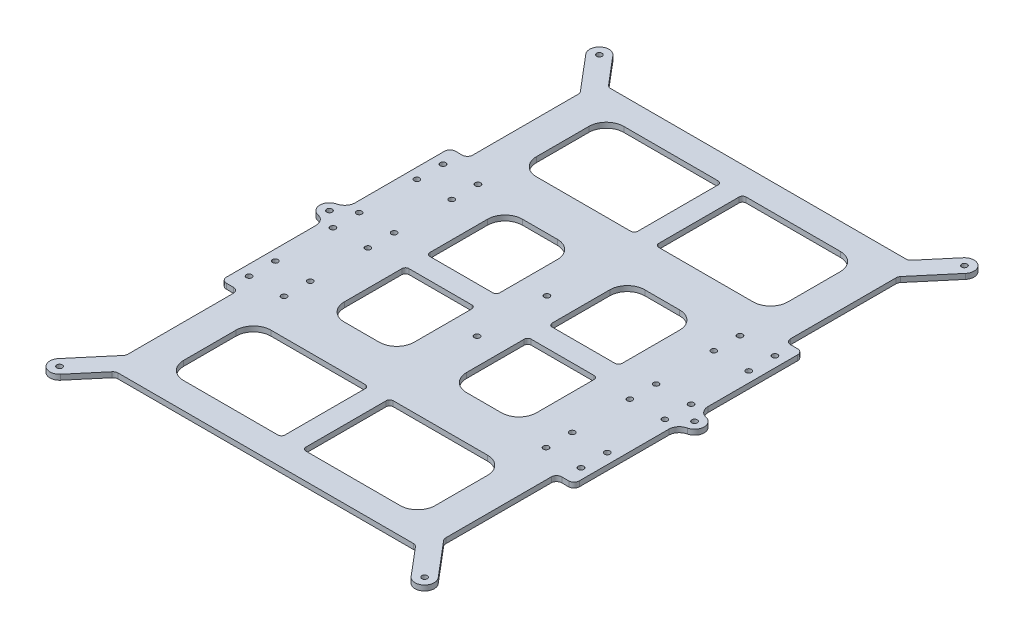
from build123d import *

# Parameters (mm, degrees)
CROQUIS1_W              = 220
CROQUIS1_H              = 320
CROQUIS1_R              = 1.55
CROQUIS1_R_2            = 1.575
SALIENTE_EXTRUIR1_DEPTH = 3
CROQUIS2_OUTSIDE_W      = 299.668
CROQUIS2_OUTSIDE_H      = 399.668
CORTAR_EXTRUIR1_DEPTH   = 3
REDONDEO1_R             = 3


with BuildPart() as part:
    # Croquis1 → Saliente-Extruir1 (new body)
    with BuildSketch(Plane(origin=(0, 0, 0), x_dir=(1, 0, 0), z_dir=(0, 1, 0))):
        with Locations((110, 160)):
            Rectangle(CROQUIS1_W, CROQUIS1_H)
        with Locations((185, 167.5)):
            Circle(CROQUIS1_R, mode=Mode.SUBTRACT)
        with Locations((205, 167.5)):
            Circle(CROQUIS1_R, mode=Mode.SUBTRACT)
        with Locations((185, 152.5)):
            Circle(CROQUIS1_R, mode=Mode.SUBTRACT)
        with Locations((205, 152.5)):
            Circle(CROQUIS1_R, mode=Mode.SUBTRACT)
        with Locations((35, 215.5)):
            Circle(CROQUIS1_R_2, mode=Mode.SUBTRACT)
        with Locations((35, 200.5)):
            Circle(CROQUIS1_R_2, mode=Mode.SUBTRACT)
        with Locations((35, 119.5)):
            Circle(CROQUIS1_R_2, mode=Mode.SUBTRACT)
        with Locations((35, 104.5)):
            Circle(CROQUIS1_R_2, mode=Mode.SUBTRACT)
        with Locations((5.5, 314.5)):
            Circle(CROQUIS1_R_2, mode=Mode.SUBTRACT)
        with Locations((214.5, 314.5)):
            Circle(CROQUIS1_R_2, mode=Mode.SUBTRACT)
        with Locations((214.5, 5.5)):
            Circle(CROQUIS1_R_2, mode=Mode.SUBTRACT)
        with Locations((5.5, 5.5)):
            Circle(CROQUIS1_R_2, mode=Mode.SUBTRACT)
        with Locations((15, 200.5)):
            Circle(CROQUIS1_R_2, mode=Mode.SUBTRACT)
        with Locations((15, 215.5)):
            Circle(CROQUIS1_R_2, mode=Mode.SUBTRACT)
        with Locations((15, 104.5)):
            Circle(CROQUIS1_R_2, mode=Mode.SUBTRACT)
        with Locations((15, 119.5)):
            Circle(CROQUIS1_R_2, mode=Mode.SUBTRACT)
        with Locations((110, 180)):
            Circle(CROQUIS1_R_2, mode=Mode.SUBTRACT)
        with Locations((110, 140)):
            Circle(CROQUIS1_R_2, mode=Mode.SUBTRACT)
        with Locations((185, 104.5)):
            Circle(CROQUIS1_R_2, mode=Mode.SUBTRACT)
        with Locations((205, 104.5)):
            Circle(CROQUIS1_R_2, mode=Mode.SUBTRACT)
        with Locations((205, 119.5)):
            Circle(CROQUIS1_R_2, mode=Mode.SUBTRACT)
        with Locations((185, 119.5)):
            Circle(CROQUIS1_R_2, mode=Mode.SUBTRACT)
        with Locations((185, 200.5)):
            Circle(CROQUIS1_R_2, mode=Mode.SUBTRACT)
        with Locations((185, 215.5)):
            Circle(CROQUIS1_R_2, mode=Mode.SUBTRACT)
        with Locations((205, 200.5)):
            Circle(CROQUIS1_R_2, mode=Mode.SUBTRACT)
        with Locations((205, 215.5)):
            Circle(CROQUIS1_R_2, mode=Mode.SUBTRACT)
        with Locations((5.5, 160)):
            Circle(CROQUIS1_R_2, mode=Mode.SUBTRACT)
        with Locations((35, 152.5)):
            Circle(CROQUIS1_R, mode=Mode.SUBTRACT)
        with Locations((15, 152.5)):
            Circle(CROQUIS1_R, mode=Mode.SUBTRACT)
        with Locations((15, 167.5)):
            Circle(CROQUIS1_R, mode=Mode.SUBTRACT)
        with Locations((35, 167.5)):
            Circle(CROQUIS1_R, mode=Mode.SUBTRACT)
        with Locations((214.5, 160)):
            Circle(CROQUIS1_R_2, mode=Mode.SUBTRACT)
    extrude(amount=SALIENTE_EXTRUIR1_DEPTH)

    # Croquis2 outside → Cortar-Extruir1 (cut)
    with BuildSketch(Plane(origin=(0, 3, 0), x_dir=(1, 0, 0), z_dir=(0, 1, 0))):
        with Locations((110, 160)):
            Rectangle(CROQUIS2_OUTSIDE_W, CROQUIS2_OUTSIDE_H)
        with BuildLine():
            Line((9, 148.77502784), (9, 94.5))
            Line((9, 94.5), (19, 94.5))
            Line((19, 94.5), (19, 30))
            Line((19, 30), (1.298802547, 9.049639413))
            ThreePointArc((1.298802547, 9.049639413), (1.950360587, 1.298802547), (9.701197453, 1.950360587))
            Line((9.701197453, 1.950360587), (24.106631311, 19))
            Line((24.106631311, 19), (195.893368689, 19))
            Line((195.893368689, 19), (210.298802547, 1.950360587))
            ThreePointArc((210.298802547, 1.950360587), (218.049639413, 1.298802547), (218.701197453, 9.049639413))
            Line((218.701197453, 9.049639413), (201, 30))
            Line((201, 30), (201, 94.5))
            Line((201, 94.5), (211, 94.5))
            Line((211, 94.5), (211, 148.77502784))
            ThreePointArc((211, 148.77502784), (212.318863014, 152.528287293), (215.695652174, 154.631535054))
            ThreePointArc((215.695652174, 154.631535054), (220, 160), (215.695652174, 165.368464946))
            ThreePointArc((215.695652174, 165.368464946), (212.318863014, 167.471712707), (211, 171.22497216))
            Line((211, 171.22497216), (211, 225.5))
            Line((211, 225.5), (201, 225.5))
            Line((201, 225.5), (201, 290))
            Line((201, 290), (218.701197453, 310.950360587))
            ThreePointArc((218.701197453, 310.950360587), (218.049639413, 318.701197453), (210.298802547, 318.049639413))
            Line((210.298802547, 318.049639413), (195.893368689, 301))
            Line((195.893368689, 301), (24.106631311, 301))
            Line((24.106631311, 301), (9.701197453, 318.049639413))
            ThreePointArc((9.701197453, 318.049639413), (1.950360587, 318.701197453), (1.298802547, 310.950360587))
            Line((1.298802547, 310.950360587), (19, 290))
            Line((19, 290), (19, 225.5))
            Line((19, 225.5), (9, 225.5))
            Line((9, 225.5), (9, 171.22497216))
            ThreePointArc((9, 171.22497216), (7.681136986, 167.471712707), (4.304347826, 165.368464946))
            ThreePointArc((4.304347826, 165.368464946), (0, 160), (4.304347826, 154.631535054))
            ThreePointArc((4.304347826, 154.631535054), (7.681136986, 152.528287293), (9, 148.77502784))
        make_face(mode=Mode.SUBTRACT)
        with BuildLine():
            Line((182, 276), (182, 246))
            ThreePointArc((182, 246), (179.071067812, 238.928932188), (172, 236))
            Line((172, 236), (118, 236))
            ThreePointArc((118, 236), (116.585786438, 236.585786438), (116, 238))
            Line((116, 238), (116, 284))
            ThreePointArc((116, 284), (116.585786438, 285.414213562), (118, 286))
            Line((118, 286), (172, 286))
            ThreePointArc((172, 286), (179.071067812, 283.071067812), (182, 276))
        make_face()
        with BuildLine():
            Line((102, 286), (48, 286))
            ThreePointArc((48, 286), (40.928932188, 283.071067812), (38, 276))
            Line((38, 276), (38, 246))
            ThreePointArc((38, 246), (40.928932188, 238.928932188), (48, 236))
            Line((48, 236), (102, 236))
            ThreePointArc((102, 236), (103.414213562, 236.585786438), (104, 238))
            Line((104, 238), (104, 284))
            ThreePointArc((104, 284), (103.414213562, 285.414213562), (102, 286))
        make_face()
        with BuildLine():
            Line((102, 84), (48, 84))
            ThreePointArc((48, 84), (40.928932188, 81.071067812), (38, 74))
            Line((38, 74), (38, 44))
            ThreePointArc((38, 44), (40.928932188, 36.928932188), (48, 34))
            Line((48, 34), (102, 34))
            ThreePointArc((102, 34), (103.414213562, 34.585786438), (104, 36))
            Line((104, 36), (104, 82))
            ThreePointArc((104, 82), (103.414213562, 83.414213562), (102, 84))
        make_face()
        with BuildLine():
            Line((116, 36), (116, 82))
            ThreePointArc((116, 82), (116.585786438, 83.414213562), (118, 84))
            Line((118, 84), (172, 84))
            ThreePointArc((172, 84), (179.071067812, 81.071067812), (182, 74))
            Line((182, 74), (182, 44))
            ThreePointArc((182, 44), (179.071067812, 36.928932188), (172, 34))
            Line((172, 34), (118, 34))
            ThreePointArc((118, 34), (116.585786438, 34.585786438), (116, 36))
        make_face()
        with BuildLine():
            Line((55, 152), (55, 119))
            ThreePointArc((55, 119), (57.928932188, 111.928932188), (65, 109))
            Line((65, 109), (85, 109))
            ThreePointArc((85, 109), (92.071067812, 111.928932188), (95, 119))
            Line((95, 119), (95, 152))
            ThreePointArc((95, 152), (94.414213562, 153.414213562), (93, 154))
            Line((93, 154), (57, 154))
            ThreePointArc((57, 154), (55.585786438, 153.414213562), (55, 152))
        make_face()
        with BuildLine():
            Line((93, 166), (57, 166))
            ThreePointArc((57, 166), (55.585786438, 166.585786438), (55, 168))
            Line((55, 168), (55, 201))
            ThreePointArc((55, 201), (57.928932188, 208.071067812), (65, 211))
            Line((65, 211), (85, 211))
            ThreePointArc((85, 211), (92.071067812, 208.071067812), (95, 201))
            Line((95, 201), (95, 168))
            ThreePointArc((95, 168), (94.414213562, 166.585786438), (93, 166))
        make_face()
        with BuildLine():
            Line((135, 109), (155, 109))
            ThreePointArc((155, 109), (162.071067812, 111.928932188), (165, 119))
            Line((165, 119), (165, 152))
            ThreePointArc((165, 152), (164.414213562, 153.414213562), (163, 154))
            Line((163, 154), (127, 154))
            ThreePointArc((127, 154), (125.585786438, 153.414213562), (125, 152))
            Line((125, 152), (125, 119))
            ThreePointArc((125, 119), (127.928932188, 111.928932188), (135, 109))
        make_face()
        with BuildLine():
            Line((127, 166), (163, 166))
            ThreePointArc((163, 166), (164.414213562, 166.585786438), (165, 168))
            Line((165, 168), (165, 201))
            ThreePointArc((165, 201), (162.071067812, 208.071067812), (155, 211))
            Line((155, 211), (135, 211))
            ThreePointArc((135, 211), (127.928932188, 208.071067812), (125, 201))
            Line((125, 201), (125, 168))
            ThreePointArc((125, 168), (125.585786438, 166.585786438), (127, 166))
        make_face()
    extrude(amount=-CORTAR_EXTRUIR1_DEPTH, mode=Mode.SUBTRACT)

    # Redondeo1
    redondeo1_edges = [part.edges().sort_by_distance(p)[0] for p in [
        (19, 1.5, -94.5),
        (9, 1.5, -94.5),
        (9, 1.5, -225.5),
        (19, 1.5, -225.5),
        (19, 1.5, -290),
        (24.106631311, 1.5, -301),
        (195.893368689, 1.5, -301),
        (201, 1.5, -290),
        (201, 1.5, -225.5),
        (211, 1.5, -225.5),
        (211, 1.5, -94.5),
        (201, 1.5, -94.5),
        (201, 1.5, -30),
        (195.893368689, 1.5, -19),
        (24.106631311, 1.5, -19),
        (19, 1.5, -30),
    ]]
    fillet(redondeo1_edges, radius=REDONDEO1_R)


solid = part.part
